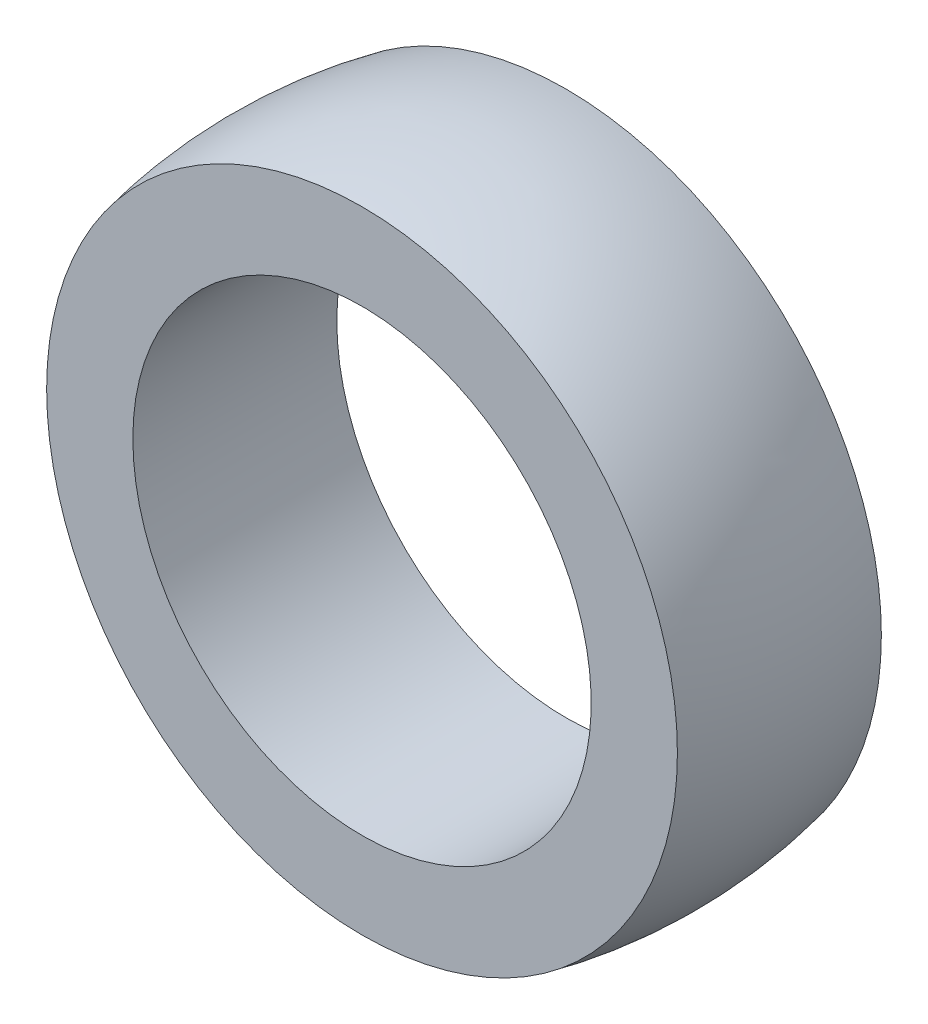
from build123d import *


with BuildPart() as part:
    # Sketch2 → Revolve1 (revolve)
    with BuildSketch(Plane(origin=(0, 0, 0), x_dir=(0, 0, -1), z_dir=(1, 0, 0))):
        with BuildLine():
            Line((-12.319, 38.1), (-12.319, 27.686))
            Line((-12.319, 27.686), (12.319, 27.686))
            Line((12.319, 27.686), (12.319, 38.1))
            ThreePointArc((12.319, 38.1), (0, 39.37), (-12.319, 38.1))
        make_face()
    revolve(axis=Axis((0, 0, 0), (0, 0, 1)))


solid = part.part
